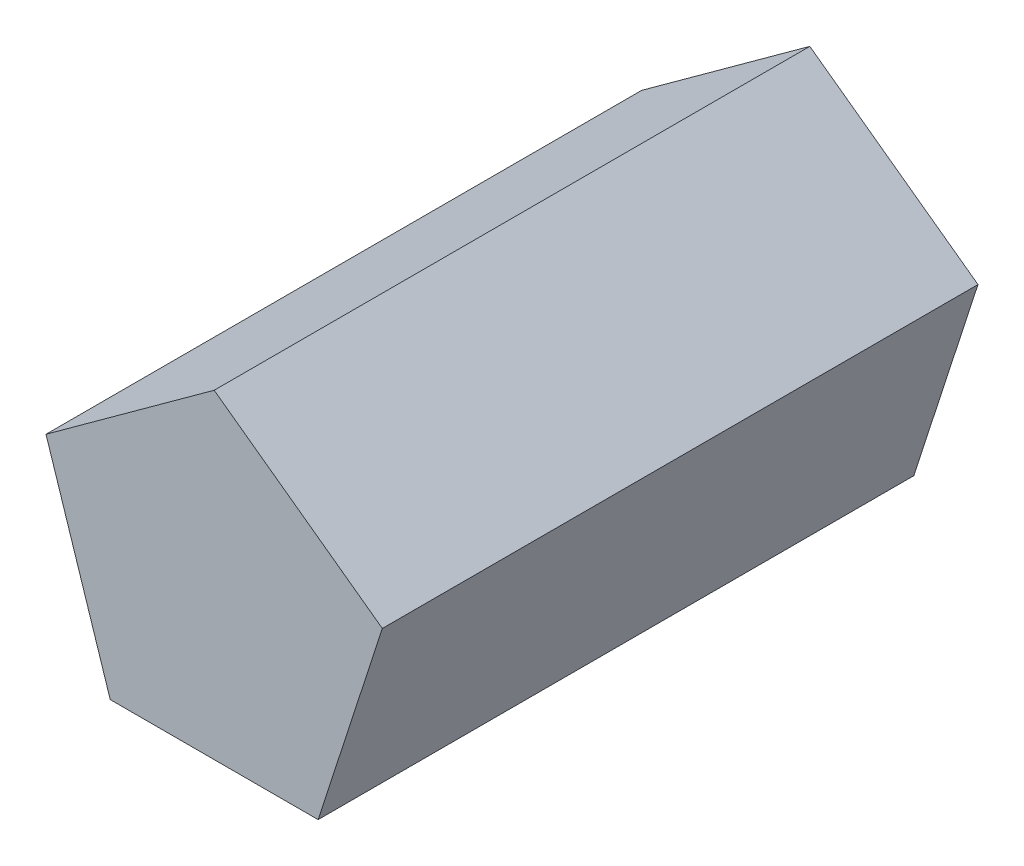
from build123d import *

# Parameters (mm, degrees)
ESTRUSIONE_ESTRUSIONE1_DEPTH = 160


with BuildPart() as part:
    # Schizzo1 → Estrusione-Estrusione1 (new body)
    with BuildSketch(Plane.XY):
        Polygon((27.919799484, -38.428307233), (45.175184524, 14.678307233), (0, 47.5), (-45.175184524, 14.678307233), (-27.919799484, -38.428307233), align=None)
    extrude(amount=ESTRUSIONE_ESTRUSIONE1_DEPTH)


solid = part.part
